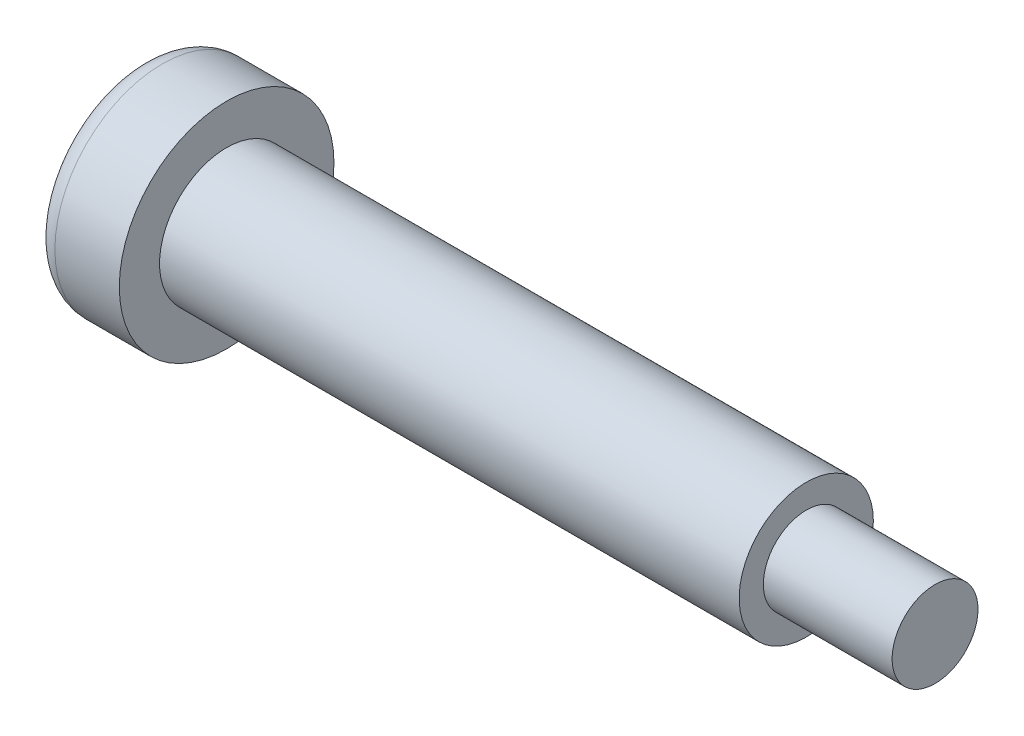
from build123d import *

# Parameters (mm, degrees)
SKETCH2_R           = 5
BOSS_EXTRUDE1_DEPTH = 4
FILLET1_R           = 1
CUT_EXTRUDE2_DEPTH  = 2.5
SKETCH4_R           = 3.125
BOSS_EXTRUDE3_DEPTH = 33
SKETCH5_R           = 3.125
SKETCH5_R_2         = 2
CUT_EXTRUDE4_DEPTH  = 6


with BuildPart() as part:
    # Sketch2 → Boss-Extrude1 (new body)
    with BuildSketch(Plane(origin=(0, 0, 0), x_dir=(0, 0, -1), z_dir=(1, 0, 0))):
        Circle(SKETCH2_R)
    extrude(amount=BOSS_EXTRUDE1_DEPTH)

    # Fillet1
    fillet1_edges = [part.edges().sort_by_distance(p)[0] for p in [
        (0, 0, 5),
    ]]
    fillet(fillet1_edges, radius=FILLET1_R)

    # Sketch3 → Cut-Extrude2 (cut)
    with BuildSketch(Plane.ZY):
        Polygon((2.075995504, 1.011719328), (0.161823113, 2.303724509), (-1.914172392, 1.292005181), (-2.075995504, -1.011719328), (-0.161823113, -2.303724509), (1.914172392, -1.292005181), align=None)
    extrude(amount=-CUT_EXTRUDE2_DEPTH, mode=Mode.SUBTRACT)

    # Sketch4 → Boss-Extrude3 (add)
    with BuildSketch(Plane(origin=(4, 0, 0), x_dir=(0, 0, -1), z_dir=(1, 0, 0))):
        Circle(SKETCH4_R)
    extrude(amount=BOSS_EXTRUDE3_DEPTH)

    # Sketch5 → Cut-Extrude4 (cut)
    with BuildSketch(Plane(origin=(37, 0, 0), x_dir=(0, 0, -1), z_dir=(1, 0, 0))):
        Circle(SKETCH5_R)
        Circle(SKETCH5_R_2, mode=Mode.SUBTRACT)
    extrude(amount=-CUT_EXTRUDE4_DEPTH, mode=Mode.SUBTRACT)


solid = part.part
